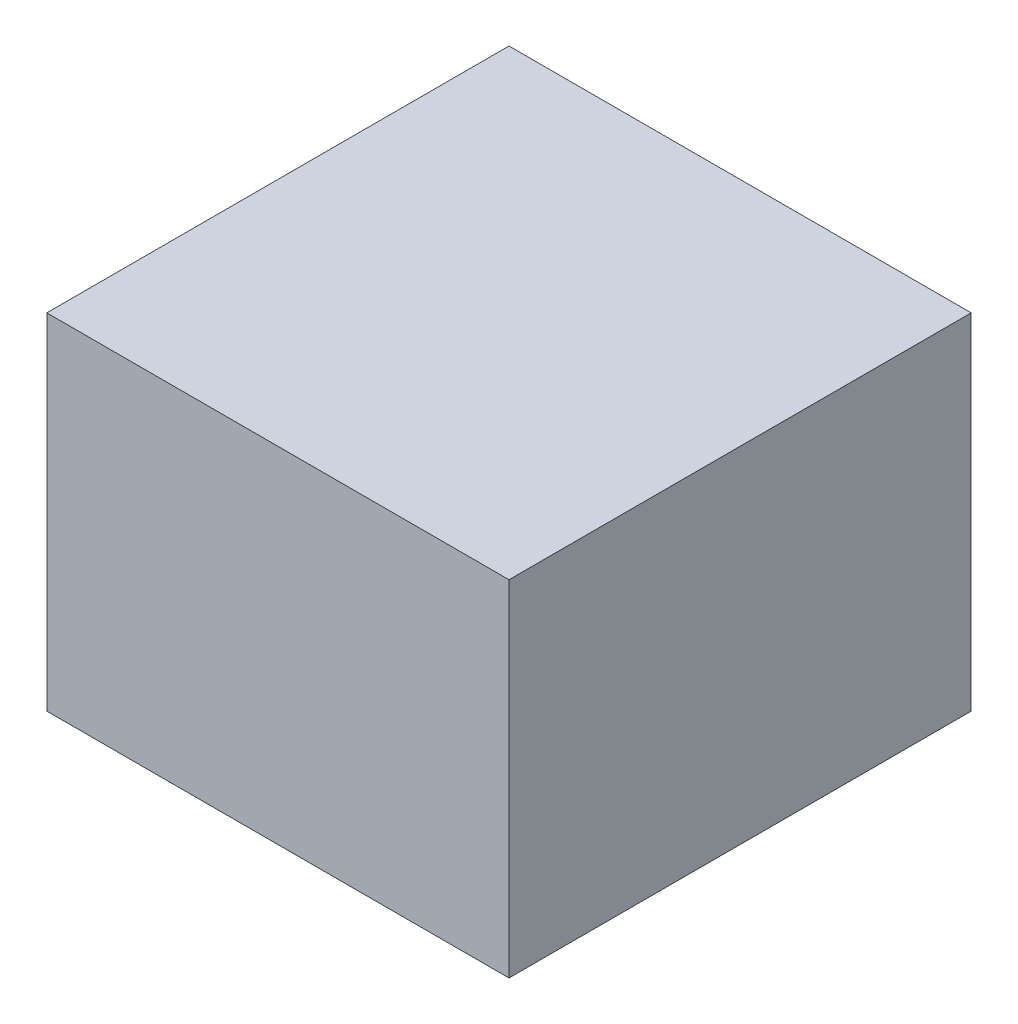
from build123d import *

# Parameters (mm, degrees)
SKETCH1_R           = 4.7
BOSS_EXTRUDE1_DEPTH = 6
SKETCH2_W           = 13.4
SKETCH2_H           = 13.4
BOSS_EXTRUDE2_DEPTH = 4


with BuildPart() as part:
    # Sketch1 → Boss-Extrude1 (new body)
    with BuildSketch(Plane(origin=(0, 0, 0), x_dir=(1, 0, 0), z_dir=(0, 1, 0))):
        Polygon((0, -6.7), (-6.7, -6.7), (-6.7, 6.7), (6.7, 6.7), (6.7, -6.7), align=None)
        Circle(SKETCH1_R, mode=Mode.SUBTRACT)
    extrude(amount=BOSS_EXTRUDE1_DEPTH)

    # Sketch2 → Boss-Extrude2 (add)
    with BuildSketch(Plane(origin=(0, 6, 0), x_dir=(1, 0, 0), z_dir=(0, 1, 0))):
        Rectangle(SKETCH2_W, SKETCH2_H)
    extrude(amount=BOSS_EXTRUDE2_DEPTH)


solid = part.part
